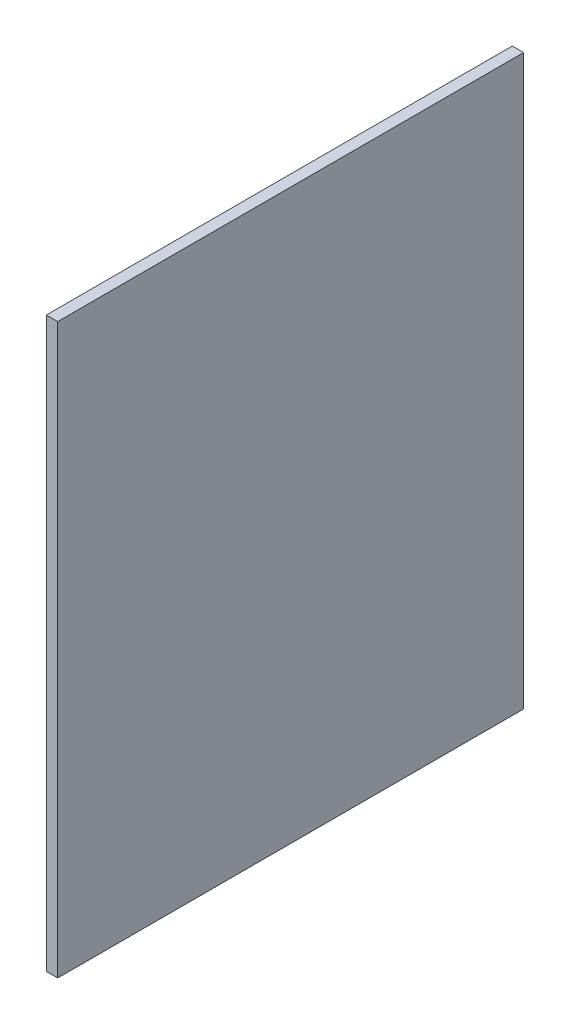
from build123d import *

# Parameters (mm, degrees)
SKETCH1_W           = 359
SKETCH1_H           = 438
BOSS_EXTRUDE1_DEPTH = 8.75


with BuildPart() as part:
    # Sketch1 → Boss-Extrude1 (new body)
    with BuildSketch(Plane(origin=(0, 0, 0), x_dir=(0, 0, -1), z_dir=(1, 0, 0))):
        with Locations((179.5, 219)):
            Rectangle(SKETCH1_W, SKETCH1_H)
    extrude(amount=BOSS_EXTRUDE1_DEPTH)


solid = part.part
